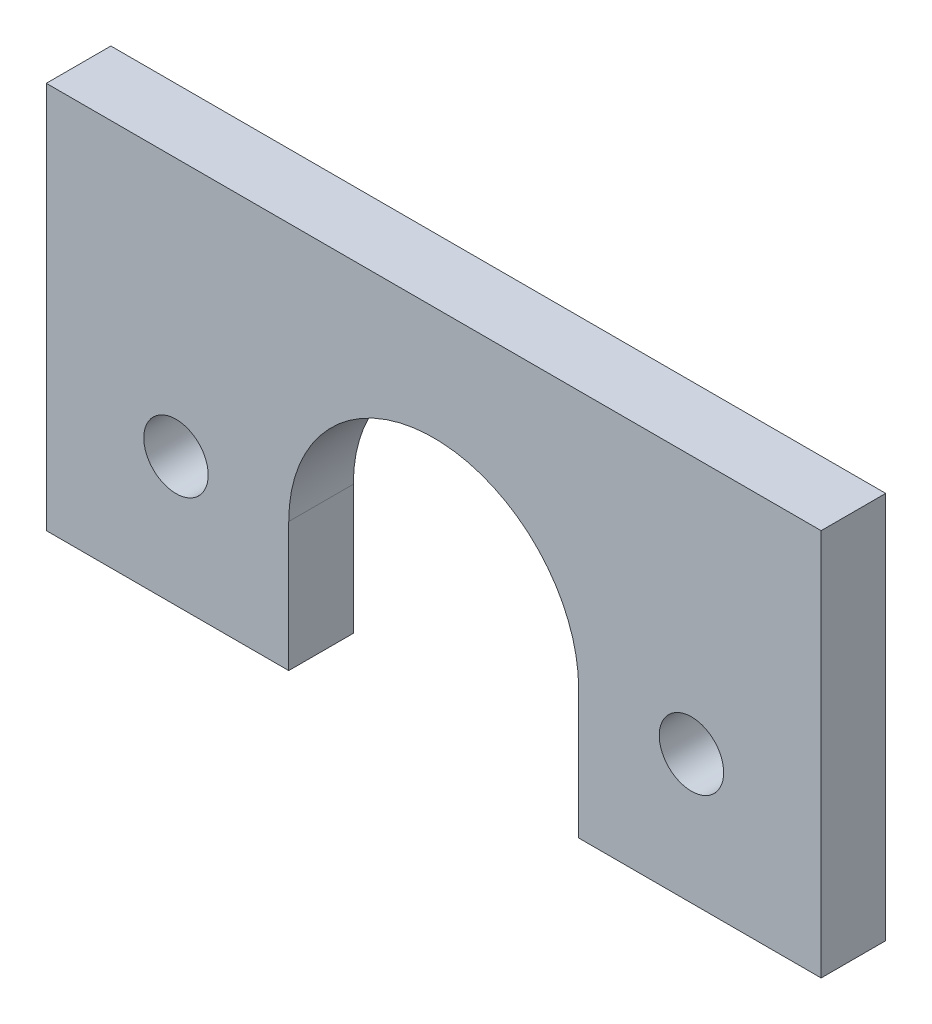
from build123d import *

# Parameters (mm, degrees)
SKETCH1_R           = 3.168199077
BOSS_EXTRUDE1_DEPTH = 6.35


with BuildPart() as part:
    # Sketch1 → Boss-Extrude1 (new body)
    with BuildSketch(Plane.XY):
        with BuildLine():
            Line((-14.256895846, 0.249783871), (-14.256895846, -12.450216129))
            Line((-14.256895846, -12.450216129), (-38.1, -12.450216129))
            Line((-38.1, -12.450216129), (-38.1, 25.649783871))
            Line((-38.1, 25.649783871), (38.1, 25.649783871))
            Line((38.1, 25.649783871), (38.1, -12.450216129))
            Line((38.1, -12.450216129), (14.256895846, -12.450216129))
            Line((14.256895846, -12.450216129), (14.256895846, 0.249783871))
            ThreePointArc((14.256895846, 0.249783871), (0, 14.506679717), (-14.256895846, 0.249783871))
        make_face()
        with Locations((-25.345592616, 0.249783871)):
            Circle(SKETCH1_R, mode=Mode.SUBTRACT)
        with Locations((25.345592616, 0.249783871)):
            Circle(SKETCH1_R, mode=Mode.SUBTRACT)
    extrude(amount=BOSS_EXTRUDE1_DEPTH)


solid = part.part
